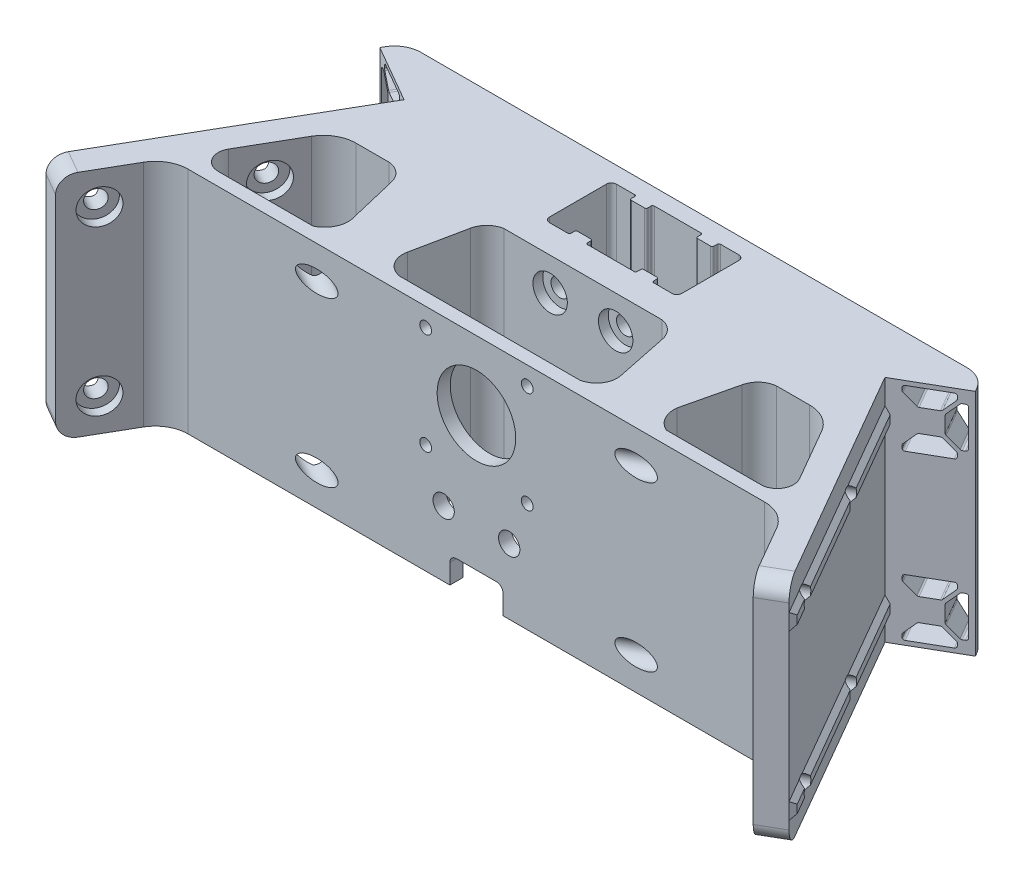
from build123d import *

# Parameters (mm, degrees)
BOSS_EXTRUDE2_DEPTH            = 70
SKETCH2_W                      = 80
SKETCH2_H                      = 5
BOSS_EXTRUDE3_DEPTH            = 1.5
BOSS_EXTRUDE3_TAPER            = 40
CBORE_FOR_M5_SHCS2_D           = 5.5
CBORE_FOR_M5_SHCS2_DEPTH       = 9.5
CBORE_FOR_M5_SHCS2_CBORE_D     = 10.5
CBORE_FOR_M5_SHCS2_CBORE_DEPTH = 3
CBORE_FOR_M5_SHCS3_D           = 5.5
CBORE_FOR_M5_SHCS3_DEPTH       = 10.5
CBORE_FOR_M5_SHCS3_CBORE_D     = 10.5
CBORE_FOR_M5_SHCS3_CBORE_DEPTH = 3
FILLET1_R                      = 5
CUT_EXTRUDE5_REACH             = 51.774
BOSS_EXTRUDE5_DEPTH            = 70
CUT_EXTRUDE7_REACH             = 94.201
SKETCH20_R                     = 3.25
CUT_EXTRUDE2_START             = -4
SKETCH8_R                      = 12
CUT_EXTRUDE2_DEPTH             = 32.5
CBORE_FOR_M3_SHCS1_D           = 3.6
CBORE_FOR_M3_SHCS1_DEPTH       = 4
CBORE_FOR_M3_SHCS1_CBORE_D     = 7.5
CBORE_FOR_M3_SHCS1_CBORE_DEPTH = 1
BOSS_EXTRUDE4_REACH            = 83.382
SKETCH12_W                     = 4
SKETCH12_H                     = 8
CUT_EXTRUDE4_REACH             = 35.9
CUT_EXTRUDE4_DIRECTION_2_REACH = 56.482
SKETCH18_R                     = 3.25
CUT_EXTRUDE6_DEPTH             = 4


with BuildPart() as part:
    # Sketch1 → Boss-Extrude2 (new body)
    with BuildSketch(Plane(origin=(0, 0, 0), x_dir=(1, 0, 0), z_dir=(0, 1, 0))):
        with BuildLine():
            Line((0, 5), (-83.381197846, 5))
            ThreePointArc((-83.381197846, 5), (-87.381197846, 3.92820323), (-90.309401077, 1))
            Line((-90.309401077, 1), (-90.886751346, 0))
            Line((-90.886751346, 0), (-73.39303819, -10.1))
            Line((-73.39303819, -10.1), (-113.39303819, -79.382032303))
            Line((-113.39303819, -79.382032303), (-106.464834959, -83.382032303))
            Line((-106.464834959, -83.382032303), (-96.660254038, -66.4))
            ThreePointArc((-96.660254038, -66.4), (-93, -62.739745962), (-88, -61.4))
            Line((-88, -61.4), (0, -61.4))
            Line((0, -61.4), (0, -57.4))
            Line((0, -57.4), (-82.803847577, -57.4))
            ThreePointArc((-82.803847577, -57.4), (-87.133974596, -54.9), (-87.133974596, -49.9))
            Line((-87.133974596, -49.9), (-77.896370289, -33.9))
            ThreePointArc((-77.896370289, -33.9), (-74.236116251, -30.239745962), (-69.236116251, -28.9))
            Line((-69.236116251, -28.9), (0, -28.9))
            Line((0, -28.9), (0, -20.4))
            Line((0, -20.4), (-7.1, -20.4))
            ThreePointArc((-7.1, -20.4), (-7.453553391, -20.253553391), (-7.6, -19.9))
            Line((-7.6, -19.9), (-7.6, -18.9))
            ThreePointArc((-7.6, -18.9), (-7.746446609, -18.546446609), (-8.1, -18.4))
            Line((-8.1, -18.4), (-12.1, -18.4))
            ThreePointArc((-12.1, -18.4), (-12.453553391, -18.546446609), (-12.6, -18.9))
            Line((-12.6, -18.9), (-12.6, -19.9))
            ThreePointArc((-12.6, -19.9), (-12.746446609, -20.253553391), (-13.1, -20.4))
            Line((-13.1, -20.4), (-18.7, -20.4))
            ThreePointArc((-18.7, -20.4), (-19.760660172, -19.960660172), (-20.2, -18.9))
            Line((-20.2, -18.9), (-20.2, -1.5))
            ThreePointArc((-20.2, -1.5), (-19.760660172, -0.439339828), (-18.7, 0))
            Line((-18.7, 0), (-13.1, 0))
            ThreePointArc((-13.1, 0), (-12.746446609, -0.146446609), (-12.6, -0.5))
            Line((-12.6, -0.5), (-12.6, -1.5))
            ThreePointArc((-12.6, -1.5), (-12.453553391, -1.853553391), (-12.1, -2))
            Line((-12.1, -2), (-8.1, -2))
            ThreePointArc((-8.1, -2), (-7.746446609, -1.853553391), (-7.6, -1.5))
            Line((-7.6, -1.5), (-7.6, -0.5))
            ThreePointArc((-7.6, -0.5), (-7.453553391, -0.146446609), (-7.1, 0))
            Line((-7.1, 0), (0, 0))
            Line((0, 0), (0, 5))
        make_face()
    extrude(amount=BOSS_EXTRUDE2_DEPTH)

    # Sketch2 → Boss-Extrude3 (add)
    with BuildSketch(Plane(origin=(-50.671350353, 0, -29.255117767), x_dir=(-0.5, 0, 0.866025404), z_dir=(-0.866025404, 0, -0.5))):
        with Locations((85.443375673, 60)):
            Rectangle(SKETCH2_W, SKETCH2_H)
        with Locations((85.443375673, 10)):
            Rectangle(SKETCH2_W, SKETCH2_H)
    extrude(amount=BOSS_EXTRUDE3_DEPTH, taper=BOSS_EXTRUDE3_TAPER)

    # CBORE for M5 SHCS2
    with Locations(Plane(origin=(-43.743147123, 0, -25.255117767), x_dir=(0.5, 0, -0.866025404), z_dir=(0.866025404, 0, 0.5))):
        with Locations((-77.54405064, 60), (-77.54405064, 10), (-115.638794752, 60), (-115.638794752, 10)):
            CounterBoreHole(CBORE_FOR_M5_SHCS2_D / 2, CBORE_FOR_M5_SHCS2_CBORE_D / 2, CBORE_FOR_M5_SHCS2_CBORE_DEPTH, depth=CBORE_FOR_M5_SHCS2_DEPTH)

    # CBORE for M5 SHCS3
    with Locations(Plane.XY.offset(28.9)):
        with Locations((-10, 20), (-10, 60)):
            CounterBoreHole(CBORE_FOR_M5_SHCS3_D / 2, CBORE_FOR_M5_SHCS3_CBORE_D / 2, CBORE_FOR_M5_SHCS3_CBORE_DEPTH, depth=CBORE_FOR_M5_SHCS3_DEPTH)

    # Fillet1
    fillet1_edges = [part.edges().sort_by_distance(p)[0] for p in [
        (-109.928936574, 70, 81.382032303),
        (-109.928936574, 0, 81.382032303),
    ]]
    fillet(fillet1_edges, radius=FILLET1_R)

    # Sketch15 → Cut-Extrude5 (cut, up to next)
    with BuildSketch(Plane(origin=(-22.721687836, 0, 39.355117767), x_dir=(0.866025404, 0, 0.5), z_dir=(-0.5, 0, 0.866025404)), mode=Mode.PRIVATE) as cut_extrude5_sk1:
        with BuildLine():
            Line((-77.210235533, 65.487), (-77.210235533, 54.513))
            ThreePointArc((-77.210235533, 54.513), (-77.002867134, 54.012368399), (-76.502235533, 53.805))
            Line((-76.502235533, 53.805), (-75.776316194, 53.805))
            ThreePointArc((-75.776316194, 53.805), (-75.505376324, 53.858893291), (-75.275684593, 54.012368399))
            Line((-75.275684593, 54.012368399), (-72.172603932, 57.11544906))
            ThreePointArc((-72.172603932, 57.11544906), (-72.019128824, 57.345140791), (-71.965235533, 57.616080661))
            Line((-71.965235533, 57.616080661), (-71.965235533, 62.383919339))
            ThreePointArc((-71.965235533, 62.383919339), (-72.019128824, 62.654859209), (-72.172603932, 62.88455094))
            Line((-72.172603932, 62.88455094), (-75.275684593, 65.987631601))
            ThreePointArc((-75.275684593, 65.987631601), (-75.505376324, 66.141106709), (-75.776316194, 66.195))
            Line((-75.776316194, 66.195), (-76.502235533, 66.195))
            ThreePointArc((-76.502235533, 66.195), (-77.002867134, 65.987631601), (-77.210235533, 65.487))
        make_face()
    cut_extrude5_tool1 = extrude(cut_extrude5_sk1.sketch, amount=-CUT_EXTRUDE5_REACH, mode=Mode.PRIVATE) & part.part
    add(cut_extrude5_tool1.solids().sort_by_distance((-87.605196, 60, 1.894607))[0], mode=Mode.SUBTRACT)
    # Sketch15 → Cut-Extrude5 (cut, up to next)
    with BuildSketch(Plane(origin=(-22.721687836, 0, 39.355117767), x_dir=(0.866025404, 0, 0.5), z_dir=(-0.5, 0, 0.866025404)), mode=Mode.PRIVATE) as cut_extrude5_sk2:
        with BuildLine():
            Line((-63.023235533, 68.7), (-73.997235533, 68.7))
            ThreePointArc((-73.997235533, 68.7), (-74.497867134, 68.492631601), (-74.705235533, 67.992))
            Line((-74.705235533, 67.992), (-74.705235533, 67.266080661))
            ThreePointArc((-74.705235533, 67.266080661), (-74.651342242, 66.995140791), (-74.497867134, 66.76544906))
            Line((-74.497867134, 66.76544906), (-71.394786473, 63.662368399))
            ThreePointArc((-71.394786473, 63.662368399), (-71.165094742, 63.508893291), (-70.894154872, 63.455))
            Line((-70.894154872, 63.455), (-66.126316194, 63.455))
            ThreePointArc((-66.126316194, 63.455), (-65.855376324, 63.508893291), (-65.625684593, 63.662368399))
            Line((-65.625684593, 63.662368399), (-62.522603932, 66.76544906))
            ThreePointArc((-62.522603932, 66.76544906), (-62.369128824, 66.995140791), (-62.315235533, 67.266080661))
            Line((-62.315235533, 67.266080661), (-62.315235533, 67.992))
            ThreePointArc((-62.315235533, 67.992), (-62.522603932, 68.492631601), (-63.023235533, 68.7))
        make_face()
    cut_extrude5_tool2 = extrude(cut_extrude5_sk2.sketch, amount=-CUT_EXTRUDE5_REACH, mode=Mode.PRIVATE) & part.part
    add(cut_extrude5_tool2.solids().sort_by_distance((-82.053292, 66.410786, 5.1))[0], mode=Mode.SUBTRACT)
    # Sketch15 → Cut-Extrude5 (cut, up to next)
    with BuildSketch(Plane(origin=(-22.721687836, 0, 39.355117767), x_dir=(0.866025404, 0, 0.5), z_dir=(-0.5, 0, 0.866025404)), mode=Mode.PRIVATE) as cut_extrude5_sk3:
        with BuildLine():
            Line((-73.997235533, 51.3), (-63.023235533, 51.3))
            ThreePointArc((-63.023235533, 51.3), (-62.522603932, 51.507368399), (-62.315235533, 52.008))
            Line((-62.315235533, 52.008), (-62.315235533, 52.733919339))
            ThreePointArc((-62.315235533, 52.733919339), (-62.369128824, 53.004859209), (-62.522603932, 53.23455094))
            Line((-62.522603932, 53.23455094), (-65.625684593, 56.337631601))
            ThreePointArc((-65.625684593, 56.337631601), (-65.855376324, 56.491106709), (-66.126316194, 56.545))
            Line((-66.126316194, 56.545), (-70.894154872, 56.545))
            ThreePointArc((-70.894154872, 56.545), (-71.165094742, 56.491106709), (-71.394786473, 56.337631601))
            Line((-71.394786473, 56.337631601), (-74.497867134, 53.23455094))
            ThreePointArc((-74.497867134, 53.23455094), (-74.651342242, 53.004859209), (-74.705235533, 52.733919339))
            Line((-74.705235533, 52.733919339), (-74.705235533, 52.008))
            ThreePointArc((-74.705235533, 52.008), (-74.497867134, 51.507368399), (-73.997235533, 51.3))
        make_face()
    cut_extrude5_tool3 = extrude(cut_extrude5_sk3.sketch, amount=-CUT_EXTRUDE5_REACH, mode=Mode.PRIVATE) & part.part
    add(cut_extrude5_tool3.solids().sort_by_distance((-82.053292, 53.589214, 5.1))[0], mode=Mode.SUBTRACT)
    # Sketch15 → Cut-Extrude5 (cut, up to next)
    with BuildSketch(Plane(origin=(-22.721687836, 0, 39.355117767), x_dir=(0.866025404, 0, 0.5), z_dir=(-0.5, 0, 0.866025404)), mode=Mode.PRIVATE) as cut_extrude5_sk4:
        with BuildLine():
            Line((-74.705235533, 17.266080661), (-74.705235533, 17.992))
            ThreePointArc((-74.705235533, 17.992), (-74.497867134, 18.492631601), (-73.997235533, 18.7))
            Line((-73.997235533, 18.7), (-63.023235533, 18.7))
            ThreePointArc((-63.023235533, 18.7), (-62.522603932, 18.492631601), (-62.315235533, 17.992))
            Line((-62.315235533, 17.992), (-62.315235533, 17.266080661))
            ThreePointArc((-62.315235533, 17.266080661), (-62.369128824, 16.995140791), (-62.522603932, 16.76544906))
            Line((-62.522603932, 16.76544906), (-65.625684593, 13.662368399))
            ThreePointArc((-65.625684593, 13.662368399), (-65.855376324, 13.508893291), (-66.126316194, 13.455))
            Line((-66.126316194, 13.455), (-70.894154872, 13.455))
            ThreePointArc((-70.894154872, 13.455), (-71.165094742, 13.508893291), (-71.394786473, 13.662368399))
            Line((-71.394786473, 13.662368399), (-74.497867134, 16.76544906))
            ThreePointArc((-74.497867134, 16.76544906), (-74.651342242, 16.995140791), (-74.705235533, 17.266080661))
        make_face()
    cut_extrude5_tool4 = extrude(cut_extrude5_sk4.sketch, amount=-CUT_EXTRUDE5_REACH, mode=Mode.PRIVATE) & part.part
    add(cut_extrude5_tool4.solids().sort_by_distance((-82.053292, 16.410786, 5.1))[0], mode=Mode.SUBTRACT)
    # Sketch15 → Cut-Extrude5 (cut, up to next)
    with BuildSketch(Plane(origin=(-22.721687836, 0, 39.355117767), x_dir=(0.866025404, 0, 0.5), z_dir=(-0.5, 0, 0.866025404)), mode=Mode.PRIVATE) as cut_extrude5_sk5:
        with BuildLine():
            Line((-62.315235533, 2.733919339), (-62.315235533, 2.008))
            ThreePointArc((-62.315235533, 2.008), (-62.522603932, 1.507368399), (-63.023235533, 1.3))
            Line((-63.023235533, 1.3), (-73.997235533, 1.3))
            ThreePointArc((-73.997235533, 1.3), (-74.497867134, 1.507368399), (-74.705235533, 2.008))
            Line((-74.705235533, 2.008), (-74.705235533, 2.733919339))
            ThreePointArc((-74.705235533, 2.733919339), (-74.651342242, 3.004859209), (-74.497867134, 3.23455094))
            Line((-74.497867134, 3.23455094), (-71.394786473, 6.337631601))
            ThreePointArc((-71.394786473, 6.337631601), (-71.165094742, 6.491106709), (-70.894154872, 6.545))
            Line((-70.894154872, 6.545), (-66.126316194, 6.545))
            ThreePointArc((-66.126316194, 6.545), (-65.855376324, 6.491106709), (-65.625684593, 6.337631601))
            Line((-65.625684593, 6.337631601), (-62.522603932, 3.23455094))
            ThreePointArc((-62.522603932, 3.23455094), (-62.369128824, 3.004859209), (-62.315235533, 2.733919339))
        make_face()
    cut_extrude5_tool5 = extrude(cut_extrude5_sk5.sketch, amount=-CUT_EXTRUDE5_REACH, mode=Mode.PRIVATE) & part.part
    add(cut_extrude5_tool5.solids().sort_by_distance((-82.053292, 3.589214, 5.1))[0], mode=Mode.SUBTRACT)
    # Sketch15 → Cut-Extrude5 (cut, up to next)
    with BuildSketch(Plane(origin=(-22.721687836, 0, 39.355117767), x_dir=(0.866025404, 0, 0.5), z_dir=(-0.5, 0, 0.866025404)), mode=Mode.PRIVATE) as cut_extrude5_sk6:
        with BuildLine():
            Line((-75.776316194, 3.805), (-76.502235533, 3.805))
            ThreePointArc((-76.502235533, 3.805), (-77.002867134, 4.012368399), (-77.210235533, 4.513))
            Line((-77.210235533, 4.513), (-77.210235533, 15.487))
            ThreePointArc((-77.210235533, 15.487), (-77.002867134, 15.987631601), (-76.502235533, 16.195))
            Line((-76.502235533, 16.195), (-75.776316194, 16.195))
            ThreePointArc((-75.776316194, 16.195), (-75.505376324, 16.141106709), (-75.275684593, 15.987631601))
            Line((-75.275684593, 15.987631601), (-72.172603932, 12.88455094))
            ThreePointArc((-72.172603932, 12.88455094), (-72.019128824, 12.654859209), (-71.965235533, 12.383919339))
            Line((-71.965235533, 12.383919339), (-71.965235533, 7.616080661))
            ThreePointArc((-71.965235533, 7.616080661), (-72.019128824, 7.345140791), (-72.172603932, 7.11544906))
            Line((-72.172603932, 7.11544906), (-75.275684593, 4.012368399))
            ThreePointArc((-75.275684593, 4.012368399), (-75.505376324, 3.858893291), (-75.776316194, 3.805))
        make_face()
    cut_extrude5_tool6 = extrude(cut_extrude5_sk6.sketch, amount=-CUT_EXTRUDE5_REACH, mode=Mode.PRIVATE) & part.part
    add(cut_extrude5_tool6.solids().sort_by_distance((-87.605196, 10, 1.894607))[0], mode=Mode.SUBTRACT)

    # Sketch17 → Boss-Extrude5 (add)
    with BuildSketch(Plane(origin=(0, 0, 0), x_dir=(1, 0, 0), z_dir=(0, 1, 0))):
        with BuildLine():
            Line((-49.731310874, -49.9), (-53.533749117, -33.9))
            ThreePointArc((-53.533749117, -33.9), (-55.519543414, -30.465958634), (-59.16423718, -28.9))
            Line((-59.16423718, -28.9), (-24.145373411, -28.9))
            ThreePointArc((-24.145373411, -28.9), (-27.493380866, -30.606417459), (-29.3026151, -33.9))
            Line((-29.3026151, -33.9), (-32.608754589, -49.9))
            ThreePointArc((-32.608754589, -49.9), (-31.643979625, -54.73226713), (-27.500937544, -57.4))
            Line((-27.500937544, -57.4), (-53.925247966, -57.4))
            ThreePointArc((-53.925247966, -57.4), (-50.604007917, -54.334602356), (-49.731310874, -49.9))
        make_face()
    extrude(amount=BOSS_EXTRUDE5_DEPTH)

    # Cut-Extrude7: up to this face of the body (flat: up to its plane)
    cut_extrude7_end = Plane(part.part.faces().sort_by_distance((-44, 35, 61.4))[0])
    # Sketch20 → Cut-Extrude7 (cut, up to the picked face)
    with BuildSketch(Plane(origin=(-43.743147123, 0, -25.255117767), x_dir=(0.5, 0, -0.866025404), z_dir=(0.866025404, 0, 0.5)), mode=Mode.PRIVATE) as cut_extrude7_sk1:
        with Locations((-77.54405064, 60)):
            Circle(SKETCH20_R)
    cut_extrude7_tool1 = split(extrude(cut_extrude7_sk1.sketch, amount=CUT_EXTRUDE7_REACH, mode=Mode.PRIVATE), bisect_by=cut_extrude7_end, keep=Keep.BOTH, mode=Mode.PRIVATE)
    add(cut_extrude7_tool1.solids().sort_by_distance((-82.515172, 60, 41.9))[0], mode=Mode.SUBTRACT)
    # Sketch20 → Cut-Extrude7 (cut, up to the picked face)
    with BuildSketch(Plane(origin=(-43.743147123, 0, -25.255117767), x_dir=(0.5, 0, -0.866025404), z_dir=(0.866025404, 0, 0.5)), mode=Mode.PRIVATE) as cut_extrude7_sk2:
        with Locations((-77.54405064, 10)):
            Circle(SKETCH20_R)
    cut_extrude7_tool2 = split(extrude(cut_extrude7_sk2.sketch, amount=CUT_EXTRUDE7_REACH, mode=Mode.PRIVATE), bisect_by=cut_extrude7_end, keep=Keep.BOTH, mode=Mode.PRIVATE)
    add(cut_extrude7_tool2.solids().sort_by_distance((-82.515172, 10, 41.9))[0], mode=Mode.SUBTRACT)

    # Mirror1: part across plane


with BuildPart() as part_1:
    add(part.part)
    add(part.part.mirror(Plane(origin=(0, 70, 20.4), x_dir=(0, 0, 1), z_dir=(-1, 0, 0))))

    # Sketch8 → Cut-Extrude2 (cut)
    with BuildSketch(Plane(origin=(0, 0, 57.4), x_dir=(-1, 0, 0), z_dir=(0, 0, -1)).offset(CUT_EXTRUDE2_START)):
        with Locations((0, 48.85)):
            Circle(SKETCH8_R)
    extrude(amount=CUT_EXTRUDE2_DEPTH, mode=Mode.SUBTRACT)

    # CBORE for M3 SHCS1
    with Locations(Plane(origin=(15.5, 33.35, 57.4), x_dir=(-1, 0, 0), z_dir=(0, 0, -1))):
        with Locations((0, 0), (31, 0), (31, 31), (0, 31)):
            CounterBoreHole(CBORE_FOR_M3_SHCS1_D / 2, CBORE_FOR_M3_SHCS1_CBORE_D / 2, CBORE_FOR_M3_SHCS1_CBORE_DEPTH, depth=CBORE_FOR_M3_SHCS1_DEPTH)

    # Sketch12 → Boss-Extrude4 (add, up to next)
    with BuildSketch(Plane.XY.offset(2), mode=Mode.PRIVATE) as boss_extrude4_sk1:
        with Locations((-10.1, 4)):
            Rectangle(SKETCH12_W, SKETCH12_H)
    boss_extrude4_tool1 = extrude(boss_extrude4_sk1.sketch, amount=BOSS_EXTRUDE4_REACH, mode=Mode.PRIVATE) - part_1.part
    add(boss_extrude4_tool1.solids().sort_by_distance((-10.1, 4, 2))[0])
    # Sketch12 → Boss-Extrude4 (add, up to next)
    with BuildSketch(Plane.XY.offset(2), mode=Mode.PRIVATE) as boss_extrude4_sk2:
        with Locations((10.1, 4)):
            Rectangle(SKETCH12_W, SKETCH12_H)
    boss_extrude4_tool2 = extrude(boss_extrude4_sk2.sketch, amount=BOSS_EXTRUDE4_REACH, mode=Mode.PRIVATE) - part_1.part
    add(boss_extrude4_tool2.solids().sort_by_distance((10.1, 4, 2))[0])

    # Sketch13 → Cut-Extrude4 (cut, up to next)
    with BuildSketch(Plane.XY.offset(28.9), mode=Mode.PRIVATE) as cut_extrude4_sk1:
        with BuildLine():
            Line((-8.1, 0), (8.1, 0))
            Line((8.1, 0), (8.1, 6))
            ThreePointArc((8.1, 6), (7.514213562, 7.414213562), (6.1, 8))
            Line((6.1, 8), (-6.1, 8))
            ThreePointArc((-6.1, 8), (-7.514213562, 7.414213562), (-8.1, 6))
            Line((-8.1, 6), (-8.1, 0))
        make_face()
    cut_extrude4_tool1 = extrude(cut_extrude4_sk1.sketch, amount=-CUT_EXTRUDE4_REACH, mode=Mode.PRIVATE) & part_1.part
    add(cut_extrude4_tool1.solids().sort_by_distance((0, 3.952298, 28.9))[0], mode=Mode.SUBTRACT)

    # Cut-Extrude4 direction 2: up to this face of the body (flat: up to its plane)
    cut_extrude4_direction_2_end = Plane(part_1.part.faces().sort_by_distance((0, 34.4092863, 61.4))[0])
    # Sketch13 → Cut-Extrude4 direction 2 (cut, up to the picked face)
    with BuildSketch(Plane.XY.offset(28.9), mode=Mode.PRIVATE) as cut_extrude4_direction_2_sk1:
        with BuildLine():
            Line((-8.1, 0), (8.1, 0))
            Line((8.1, 0), (8.1, 6))
            ThreePointArc((8.1, 6), (7.514213562, 7.414213562), (6.1, 8))
            Line((6.1, 8), (-6.1, 8))
            ThreePointArc((-6.1, 8), (-7.514213562, 7.414213562), (-8.1, 6))
            Line((-8.1, 6), (-8.1, 0))
        make_face()
    cut_extrude4_direction_2_tool1 = split(extrude(cut_extrude4_direction_2_sk1.sketch, amount=CUT_EXTRUDE4_DIRECTION_2_REACH, mode=Mode.PRIVATE), bisect_by=cut_extrude4_direction_2_end, keep=Keep.BOTH, mode=Mode.PRIVATE)
    add(cut_extrude4_direction_2_tool1.solids().sort_by_distance((0, 3.952298, 28.9))[0], mode=Mode.SUBTRACT)

    # Sketch18 → Cut-Extrude6 (cut)
    with BuildSketch(Plane.XY.offset(61.4)):
        with Locations((-10, 20)):
            Circle(SKETCH18_R)
        with Locations((10, 20)):
            Circle(SKETCH18_R)
    extrude(amount=-CUT_EXTRUDE6_DEPTH, mode=Mode.SUBTRACT)


solid = part_1.part
